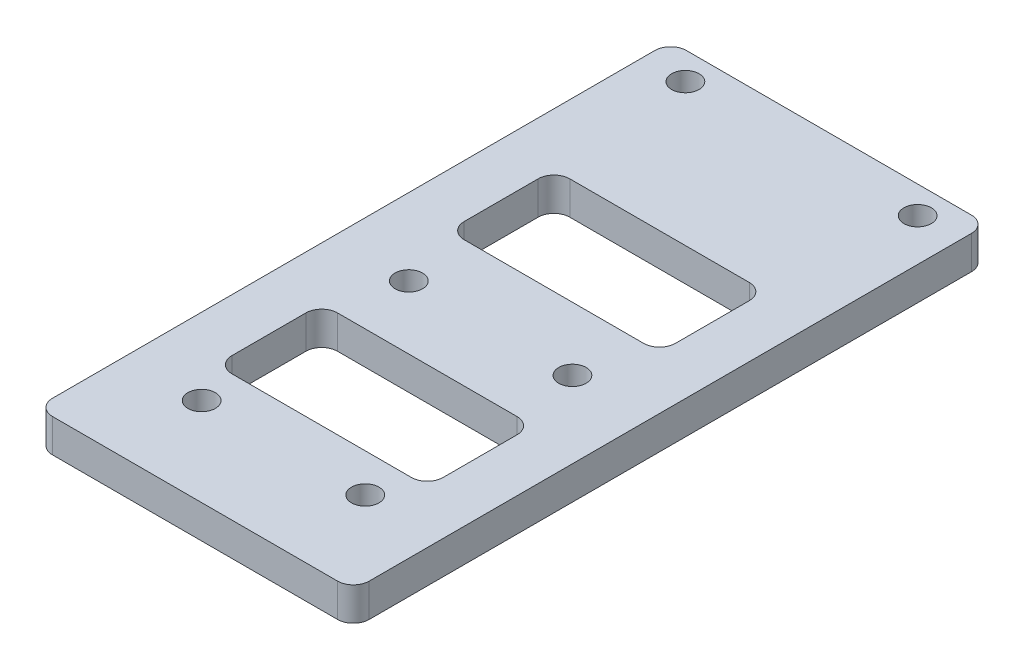
from build123d import *

# Parameters (mm, degrees)
SKETCH1_W           = 30
SKETCH1_H           = 60.05
BOSS_EXTRUDE1_DEPTH = 3.15
CUT_EXTRUDE1_DEPTH  = 3.15
SKETCH3_R           = 1.3
CUT_EXTRUDE2_DEPTH  = 3.15
FILLET1_R           = 1.5
SKETCH5_R           = 1.3
CUT_EXTRUDE3_DEPTH  = 3.15


with BuildPart() as part:
    # Sketch1 → Boss-Extrude1 (new body)
    with BuildSketch(Plane(origin=(0, 0, 0), x_dir=(1, 0, 0), z_dir=(0, 1, 0))):
        Rectangle(SKETCH1_W, SKETCH1_H)
    extrude(amount=-BOSS_EXTRUDE1_DEPTH)

    # Sketch2 → Cut-Extrude1 (cut)
    with BuildSketch(Plane(origin=(0, 0, 0), x_dir=(1, 0, 0), z_dir=(0, 1, 0))):
        with BuildLine():
            Line((-8.5, 13.975), (8.5, 13.975))
            ThreePointArc((8.5, 13.975), (9.560660172, 13.535660172), (10, 12.475))
            Line((10, 12.475), (10, 5.475))
            ThreePointArc((10, 5.475), (9.560660172, 4.414339828), (8.5, 3.975))
            Line((8.5, 3.975), (-8.5, 3.975))
            ThreePointArc((-8.5, 3.975), (-9.560660172, 4.414339828), (-10, 5.475))
            Line((-10, 5.475), (-10, 12.475))
            ThreePointArc((-10, 12.475), (-9.560660172, 13.535660172), (-8.5, 13.975))
        make_face()
        with BuildLine():
            Line((-8.5, -8.025), (8.5, -8.025))
            ThreePointArc((8.5, -8.025), (9.560660172, -8.464339828), (10, -9.525))
            Line((10, -9.525), (10, -16.525))
            ThreePointArc((10, -16.525), (9.560660172, -17.585660172), (8.5, -18.025))
            Line((8.5, -18.025), (-8.5, -18.025))
            ThreePointArc((-8.5, -18.025), (-9.560660172, -17.585660172), (-10, -16.525))
            Line((-10, -16.525), (-10, -9.525))
            ThreePointArc((-10, -9.525), (-9.560660172, -8.464339828), (-8.5, -8.025))
        make_face()
    extrude(amount=-CUT_EXTRUDE1_DEPTH, mode=Mode.SUBTRACT)

    # Sketch3 → Cut-Extrude2 (cut)
    with BuildSketch(Plane(origin=(0, 0, 0), x_dir=(1, 0, 0), z_dir=(0, 1, 0))):
        with Locations((-11, 27.425)):
            Circle(SKETCH3_R)
        with Locations((11, 27.425)):
            Circle(SKETCH3_R)
    extrude(amount=-CUT_EXTRUDE2_DEPTH, mode=Mode.SUBTRACT)

    # Fillet1
    fillet1_edges = [part.edges().sort_by_distance(p)[0] for p in [
        (-15, -1.575, -30.025),
        (15, -1.575, -30.025),
        (15, -1.575, 30.025),
        (-15, -1.575, 30.025),
    ]]
    fillet(fillet1_edges, radius=FILLET1_R)

    # Sketch5 → Cut-Extrude3 (cut)
    with BuildSketch(Plane(origin=(0, 0, 0), x_dir=(1, 0, 0), z_dir=(0, 1, 0))):
        with Locations((-7.75, -2.025)):
            Circle(SKETCH5_R)
        with Locations((7.75, -2.025)):
            Circle(SKETCH5_R)
        with Locations((-7.75, -21.65)):
            Circle(SKETCH5_R)
        with Locations((7.75, -21.65)):
            Circle(SKETCH5_R)
    extrude(amount=-CUT_EXTRUDE3_DEPTH, mode=Mode.SUBTRACT)


solid = part.part
